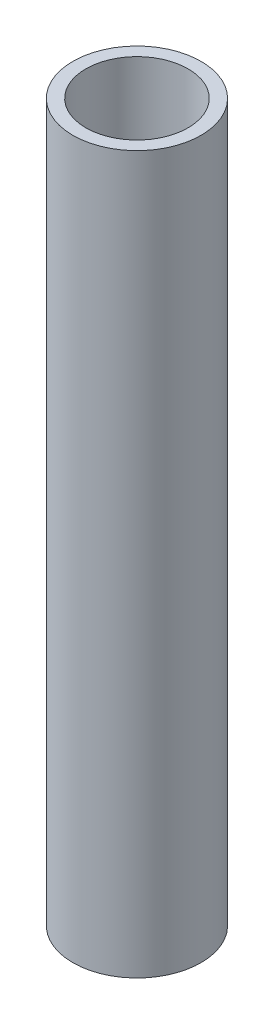
from build123d import *

# Parameters (mm, degrees)
SKETCH1_R           = 16.7005
SKETCH1_R_2         = 13.3223
BOSS_EXTRUDE1_DEPTH = 186.69


with BuildPart() as part:
    # Sketch1 → Boss-Extrude1 (new body)
    with BuildSketch(Plane(origin=(0, 0, 0), x_dir=(1, 0, 0), z_dir=(0, 1, 0))):
        Circle(SKETCH1_R)
        Circle(SKETCH1_R_2, mode=Mode.SUBTRACT)
    extrude(amount=BOSS_EXTRUDE1_DEPTH)


solid = part.part
